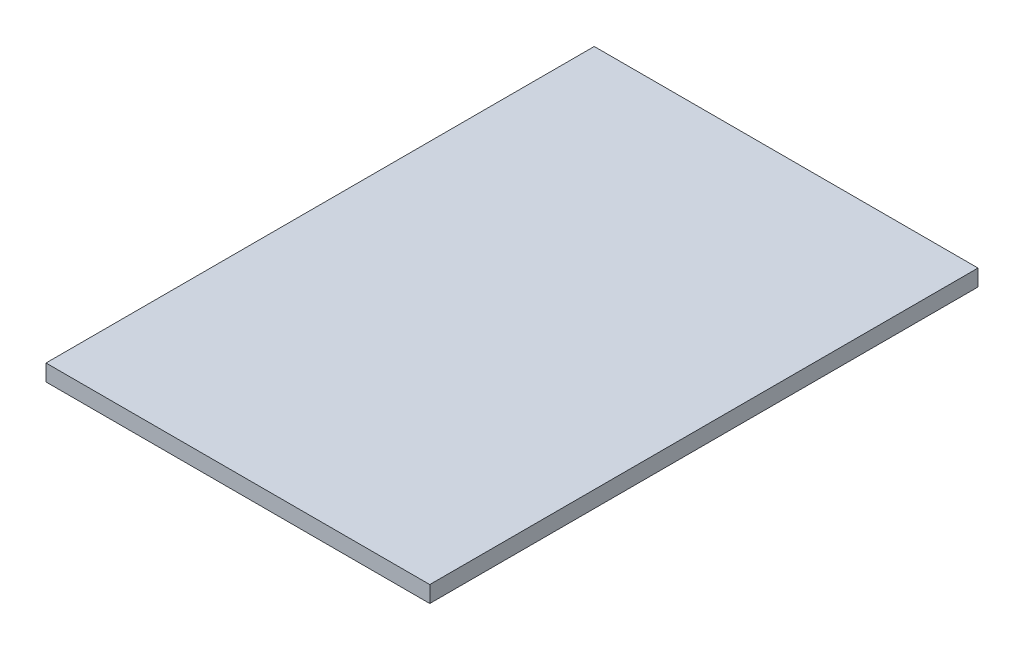
from build123d import *

# Parameters (mm, degrees)
CROQUIS1_W              = 700
CROQUIS1_H              = 1000
SALIENTE_EXTRUIR1_DEPTH = 20
CROQUIS2_W              = 700
CROQUIS2_H              = 1000
SALIENTE_EXTRUIR2_DEPTH = 10


with BuildPart() as part:
    # Croquis1 → Saliente-Extruir1 (new body)
    with BuildSketch(Plane(origin=(0, 0, 0), x_dir=(1, 0, 0), z_dir=(0, 1, 0))):
        Rectangle(CROQUIS1_W, CROQUIS1_H)
    extrude(amount=SALIENTE_EXTRUIR1_DEPTH)

    # Croquis2 → Saliente-Extruir2 (add)
    with BuildSketch(Plane(origin=(0, 0, 0), x_dir=(-1, 0, 0), z_dir=(0, -1, 0))):
        Rectangle(CROQUIS2_W, CROQUIS2_H)
    extrude(amount=SALIENTE_EXTRUIR2_DEPTH)


solid = part.part
